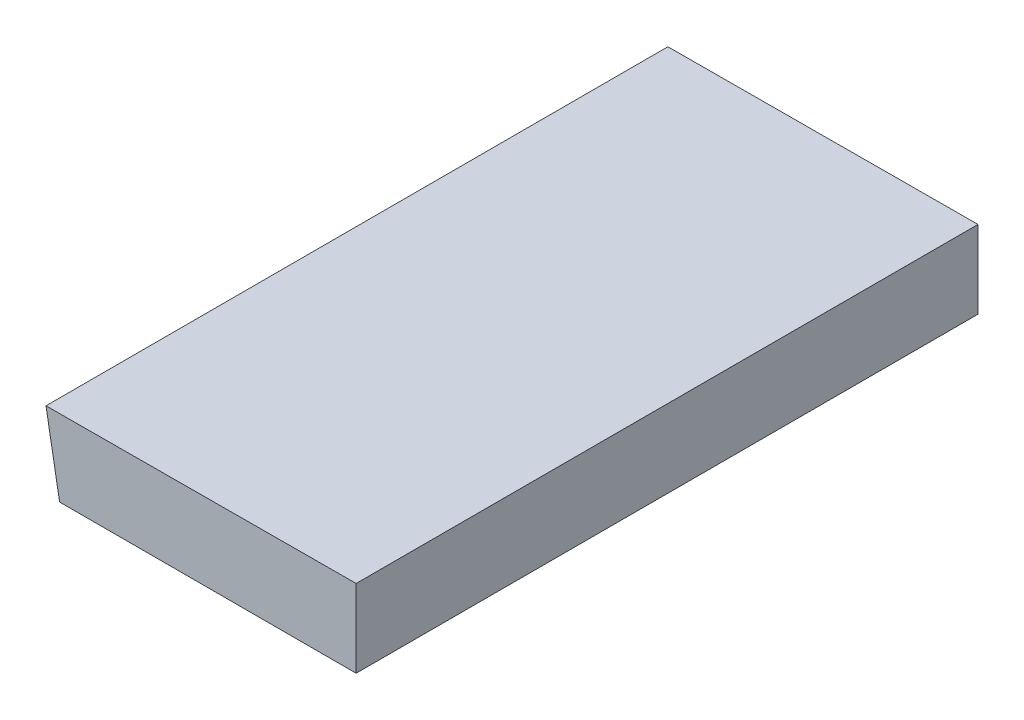
from build123d import *

# Parameters (mm, degrees)
BOSS_EXTRUDE1_DEPTH = 6.35


with BuildPart() as part:
    # Sketch1 → Boss-Extrude1 (new body)
    with BuildSketch(Plane.XY):
        Polygon((0, 0), (3.02795104, 0), (3.02795104, 0.794), (-0.138803546, 0.781773353), align=None)
    extrude(amount=BOSS_EXTRUDE1_DEPTH)


solid = part.part
